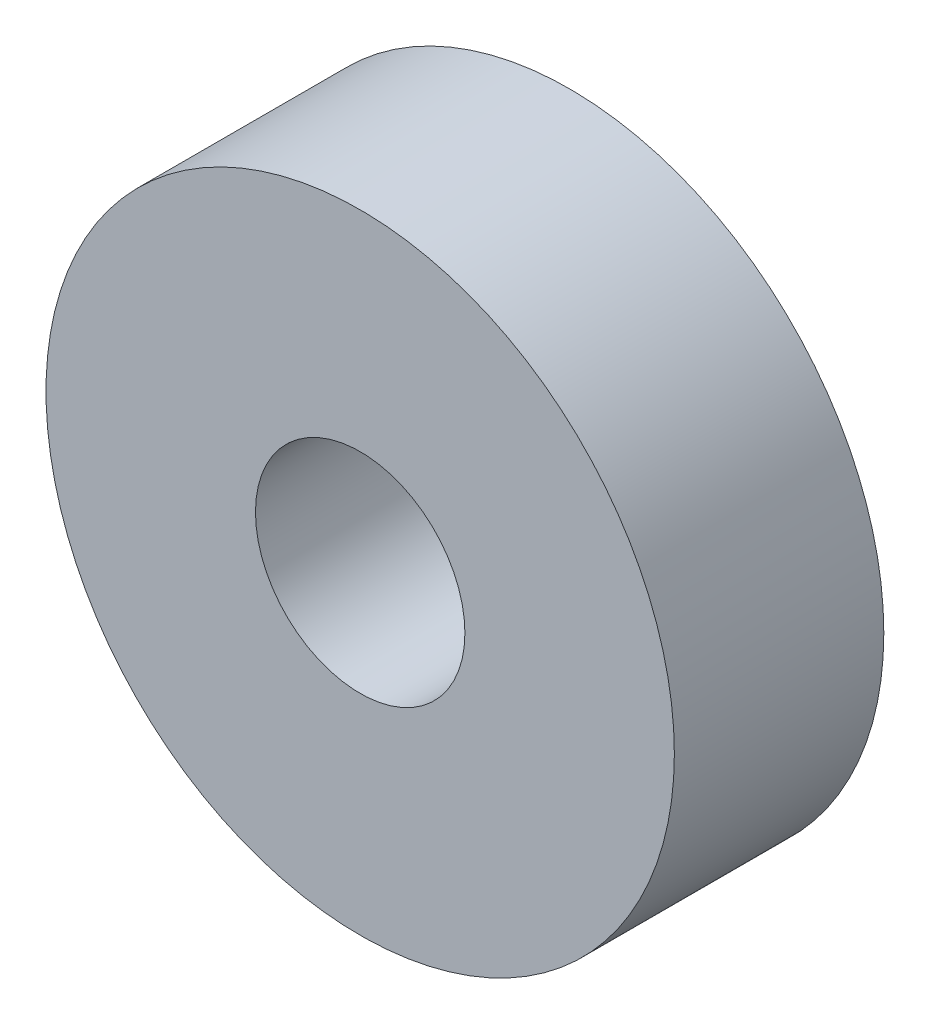
from build123d import *

# Parameters (mm, degrees)
SKETCH_1_R      = 6
SKETCH_1_R_2    = 2
EXTRUDE_1_DEPTH = 4


with BuildPart() as part:
    # 草图1 → 凸台-拉伸1 (new body)
    with BuildSketch(Plane.XY):
        Circle(SKETCH_1_R)
        Circle(SKETCH_1_R_2, mode=Mode.SUBTRACT)
    extrude(amount=EXTRUDE_1_DEPTH)


solid = part.part
